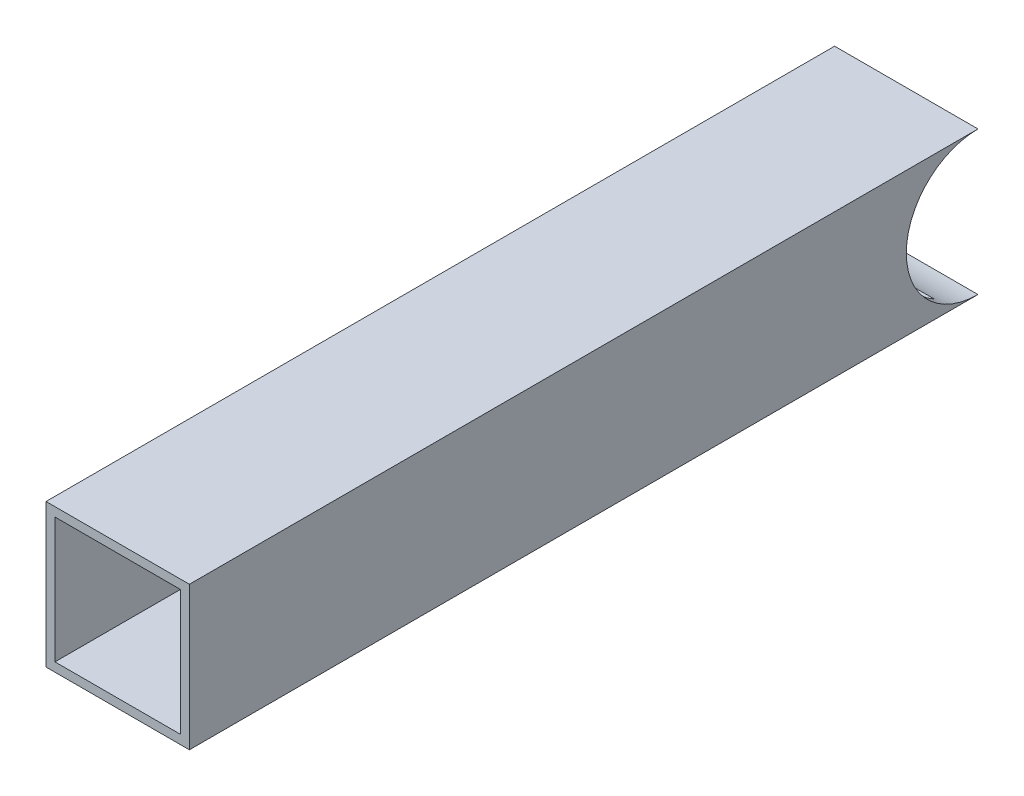
from build123d import *

# Parameters (mm, degrees)
SKETCH1_W           = 50.8
SKETCH1_H           = 50.8
SKETCH1_W_2         = 44.45
SKETCH1_H_2         = 44.45
BOSS_EXTRUDE1_DEPTH = 279.4
SKETCH2_R           = 25.4
CUT_EXTRUDE1_DEPTH  = 139.7


with BuildPart() as part:
    # Sketch1 → Boss-Extrude1 (new body)
    with BuildSketch(Plane.XY):
        Rectangle(SKETCH1_W, SKETCH1_H)
        Rectangle(SKETCH1_W_2, SKETCH1_H_2, mode=Mode.SUBTRACT)
    extrude(amount=BOSS_EXTRUDE1_DEPTH)

    # Sketch2 → Cut-Extrude1 (cut, symmetric)
    with BuildSketch(Plane(origin=(0, 0, 0), x_dir=(0, 0, -1), z_dir=(1, 0, 0))):
        Circle(SKETCH2_R)
    extrude(amount=CUT_EXTRUDE1_DEPTH, both=True, mode=Mode.SUBTRACT)


solid = part.part
